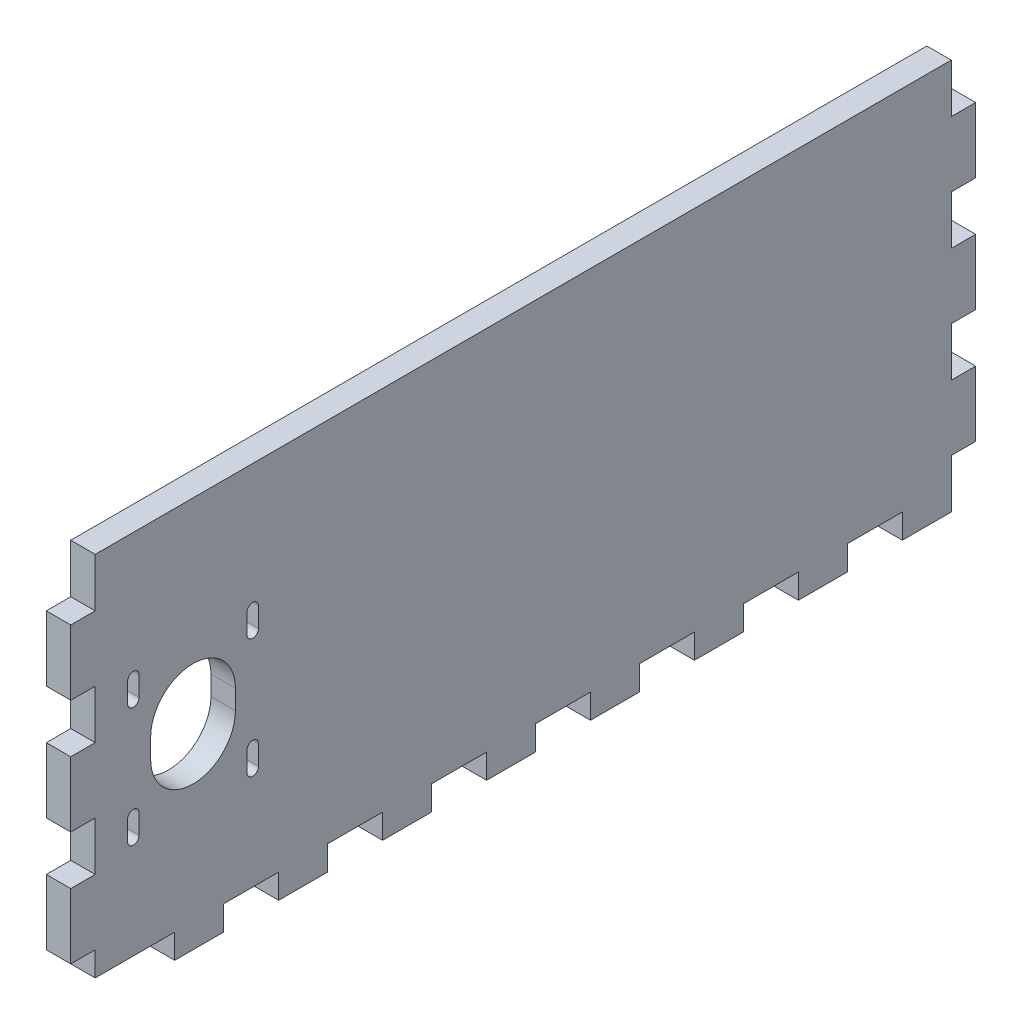
from build123d import *

# Parameters (mm, degrees)
SKETCH1_W               = 44.958
SKETCH1_H               = 304.8
BOSS_EXTRUDE1_DEPTH     = 6.35
SKETCH2_W               = 6.35
SKETCH2_H               = 101.6
BOSS_EXTRUDE2_DEPTH     = 6.35
SKETCH3_W               = 222.25
SKETCH3_H               = 6.35
BOSS_EXTRUDE3_DEPTH     = 38.608
SKETCH8_W               = 6.35
SKETCH8_H               = 213.451350416
CUT_EXTRUDE4_DEPTH      = 1
CUT_EXTRUDE4_DEPTH_BACK = 235.95
SKETCH6_W               = 6.35
SKETCH6_H               = 12.7
CUT_EXTRUDE5_DEPTH      = 6.35
SKETCH4_3_W             = 6.35
SKETCH4_3_H             = 14.2875
SKETCH4_3_H_2           = 6.35
CUT_EXTRUDE6_DEPTH      = 6.35


with BuildPart() as part:
    # Sketch1 → Boss-Extrude1 (new body)
    with BuildSketch(Plane.XY):
        with Locations((-6.477, 3.048)):
            Rectangle(SKETCH1_W, SKETCH1_H)
        with BuildLine():
            Line((-3.302, 133.858), (-3.302, -143.002))
            Line((-3.302, -143.002), (3.302, -143.002))
            Line((3.302, -143.002), (3.302, 143.002))
            Line((3.302, 143.002), (-16.256, 143.002))
            Line((-16.256, 143.002), (-16.256, 136.398))
            Line((-16.256, 136.398), (-5.842, 136.398))
            ThreePointArc((-5.842, 136.398), (-4.045948776, 135.654051224), (-3.302, 133.858))
        make_face(mode=Mode.SUBTRACT)
    extrude(amount=BOSS_EXTRUDE1_DEPTH)

    # Sketch2 → Boss-Extrude2 (add)
    with BuildSketch(Plane(origin=(16.002, 0, 0), x_dir=(0, 0, -1), z_dir=(1, 0, 0))):
        Polygon((222.25, -60.452), (222.25, -47.752), (0, -47.752), (0, -149.352), (222.25, -149.352), (222.25, -136.652), (228.6, -136.652), (228.6, -119.718666667), (222.25, -119.718666667), (222.25, -107.018666667), (228.6, -107.018666667), (228.6, -90.085333333), (222.25, -90.085333333), (222.25, -77.385333333), (228.6, -77.385333333), (228.6, -60.452), align=None)
        with BuildLine():
            ThreePointArc((11.4, -116.592), (9.9, -118.092), (8.4, -116.592))
            Line((8.4, -116.592), (8.4, -111.512))
            ThreePointArc((8.4, -111.512), (9.9, -110.012), (11.4, -111.512))
            Line((11.4, -111.512), (11.4, -116.592))
        make_face(mode=Mode.SUBTRACT)
        with BuildLine():
            Line((42.4, -111.512), (42.4, -116.592))
            ThreePointArc((42.4, -116.592), (40.9, -118.092), (39.4, -116.592))
            Line((39.4, -116.592), (39.4, -111.512))
            ThreePointArc((39.4, -111.512), (40.9, -110.012), (42.4, -111.512))
        make_face(mode=Mode.SUBTRACT)
        with BuildLine():
            ThreePointArc((36.4, -101.092), (25.4, -112.092), (14.4, -101.092))
            Line((14.4, -101.092), (14.4, -96.012))
            ThreePointArc((14.4, -96.012), (25.4, -85.012), (36.4, -96.012))
            Line((36.4, -96.012), (36.4, -101.092))
        make_face(mode=Mode.SUBTRACT)
        with BuildLine():
            ThreePointArc((11.4, -85.592), (9.9, -87.092), (8.4, -85.592))
            Line((8.4, -85.592), (8.4, -80.512))
            ThreePointArc((8.4, -80.512), (9.9, -79.012), (11.4, -80.512))
            Line((11.4, -80.512), (11.4, -85.592))
        make_face(mode=Mode.SUBTRACT)
        with BuildLine():
            ThreePointArc((42.4, -85.592), (40.9, -87.092), (39.4, -85.592))
            Line((39.4, -85.592), (39.4, -80.512))
            ThreePointArc((39.4, -80.512), (40.9, -79.012), (42.4, -80.512))
            Line((42.4, -80.512), (42.4, -85.592))
        make_face(mode=Mode.SUBTRACT)
        with Locations((-3.175, -98.552)):
            Rectangle(SKETCH2_W, SKETCH2_H)
    extrude(amount=-BOSS_EXTRUDE2_DEPTH)

    # Sketch3 → Boss-Extrude3 (add)
    with BuildSketch(Plane.ZY.offset(-9.652)):
        with Locations((-111.125, -146.177)):
            Rectangle(SKETCH3_W, SKETCH3_H)
    extrude(amount=BOSS_EXTRUDE3_DEPTH)

    # Sketch8 → Cut-Extrude4 (cut, two sides)
    with BuildSketch(Plane.XY.offset(6.35)) as cut_extrude4_sk:
        Polygon((-28.956, -149.352), (9.652, -149.352), (9.652, -47.752), (9.652, 155.448), (-28.956, 155.448), align=None)
        with BuildLine():
            Line((-16.256, 136.398), (-16.256, 143.002))
            Line((-16.256, 143.002), (3.302, 143.002))
            Line((3.302, 143.002), (3.302, -143.002))
            Line((3.302, -143.002), (-3.302, -143.002))
            Line((-3.302, -143.002), (-3.302, 133.858))
            ThreePointArc((-3.302, 133.858), (-4.045948776, 135.654051224), (-5.842, 136.398))
            Line((-5.842, 136.398), (-16.256, 136.398))
        make_face(mode=Mode.SUBTRACT)
        Polygon((-54.223542679, -149.352), (-28.956, -149.352), (-28.956, 155.448), (9.652, 155.448), (9.652, 165.699350416), (-54.223542679, 165.699350416), align=None)
        with Locations((12.827, 58.973675208)):
            Rectangle(SKETCH8_W, SKETCH8_H)
    extrude(amount=CUT_EXTRUDE4_DEPTH, mode=Mode.SUBTRACT)
    extrude(cut_extrude4_sk.sketch, amount=-CUT_EXTRUDE4_DEPTH_BACK, mode=Mode.SUBTRACT)

    # Sketch6 → Cut-Extrude5 (cut)
    with BuildSketch(Plane.XY.offset(6.35)):
        with Locations((12.827, -54.102)):
            Rectangle(SKETCH6_W, SKETCH6_H)
        with Locations((12.827, -83.735333333)):
            Rectangle(SKETCH6_W, SKETCH6_H)
        with Locations((12.827, -113.368666667)):
            Rectangle(SKETCH6_W, SKETCH6_H)
        with Locations((12.827, -143.002)):
            Rectangle(SKETCH6_W, SKETCH6_H)
    extrude(amount=-CUT_EXTRUDE5_DEPTH, mode=Mode.SUBTRACT)

    # Sketch4_3 → Cut-Extrude6 (cut)
    with BuildSketch(Plane.XZ.offset(149.352)):
        with Locations((12.827, -13.49375)):
            Rectangle(SKETCH4_3_W, SKETCH4_3_H)
        with Locations((12.827, -40.48125)):
            Rectangle(SKETCH4_3_W, SKETCH4_3_H)
        with Locations((12.827, -67.46875)):
            Rectangle(SKETCH4_3_W, SKETCH4_3_H)
        with Locations((12.827, -94.45625)):
            Rectangle(SKETCH4_3_W, SKETCH4_3_H)
        with Locations((12.827, -121.44375)):
            Rectangle(SKETCH4_3_W, SKETCH4_3_H)
        with Locations((12.827, -148.43125)):
            Rectangle(SKETCH4_3_W, SKETCH4_3_H)
        with Locations((12.827, -175.41875)):
            Rectangle(SKETCH4_3_W, SKETCH4_3_H)
        with Locations((12.827, -202.40625)):
            Rectangle(SKETCH4_3_W, SKETCH4_3_H)
        with Locations((12.827, -3.175)):
            Rectangle(SKETCH4_3_W, SKETCH4_3_H_2)
        with Locations((12.827, 3.175)):
            Rectangle(SKETCH4_3_W, SKETCH4_3_H_2)
    extrude(amount=-CUT_EXTRUDE6_DEPTH, mode=Mode.SUBTRACT)


solid = part.part
